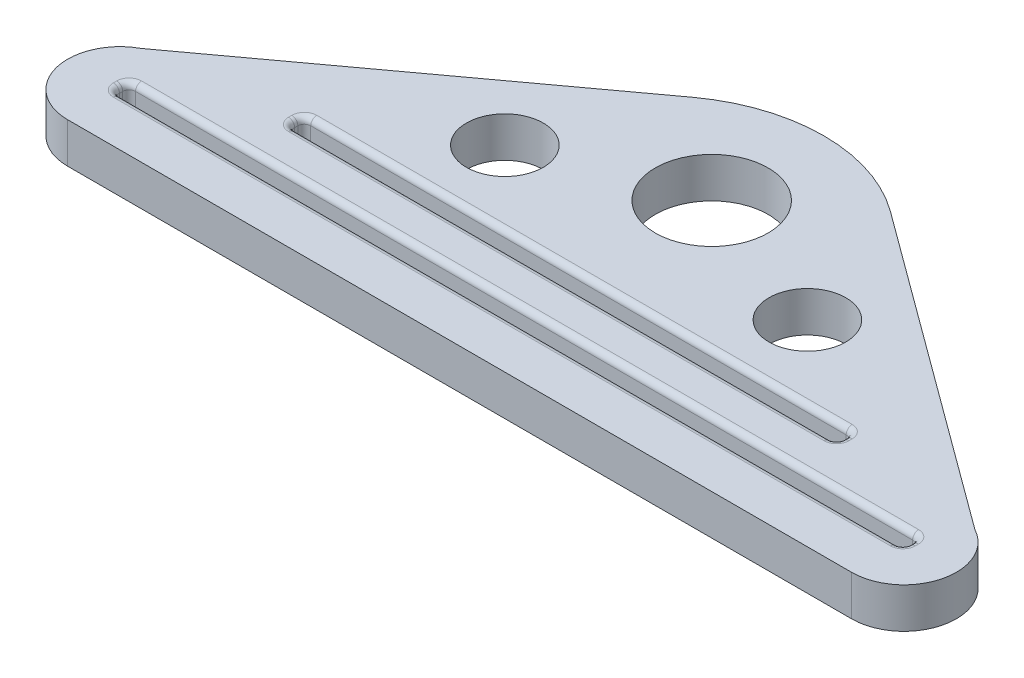
from build123d import *

# Parameters (mm, degrees)
SKETCH1_R           = 4.76718426
SKETCH1_R_2         = 7
BOSS_EXTRUDE1_DEPTH = 5
FILLET1_R           = 0.75


with BuildPart() as part:
    # Sketch1 → Boss-Extrude1 (new body)
    with BuildSketch(Plane(origin=(0, 0, 0), x_dir=(1, 0, 0), z_dir=(0, 1, 0))):
        with BuildLine():
            Line((47.691636032, 41.150111797), (8.289521266, 12.226314063))
            ThreePointArc((8.289521266, 12.226314063), (5.06151148, 4.914289025), (11.365123199, 0))
            Line((11.365123199, 0), (108.634876801, 0))
            ThreePointArc((108.634876801, 0), (114.93848852, 4.914289025), (111.710478734, 12.226314063))
            Line((111.710478734, 12.226314063), (72.308363968, 41.150111797))
            ThreePointArc((72.308363968, 41.150111797), (60, 45.182757312), (47.691636032, 41.150111797))
        make_face()
        with BuildLine():
            Line((108.2, 6), (60, 6))
            Line((60, 6), (11.8, 6))
            ThreePointArc((11.8, 6), (11.234314575, 6.234314575), (11, 6.8))
            Line((11, 6.8), (11, 7.2))
            ThreePointArc((11, 7.2), (11.234314575, 7.765685425), (11.8, 8))
            Line((11.8, 8), (108.2, 8))
            ThreePointArc((108.2, 8), (108.765685425, 7.765685425), (109, 7.2))
            Line((109, 7.2), (109, 6.8))
            ThreePointArc((109, 6.8), (108.765685425, 6.234314575), (108.2, 6))
        make_face(mode=Mode.SUBTRACT)
        with BuildLine():
            Line((92.782659438, 13.175291488), (26.35604376, 13.175291488))
            ThreePointArc((26.35604376, 13.175291488), (25.790358335, 13.409606063), (25.55604376, 13.975291488))
            Line((25.55604376, 13.975291488), (25.55604376, 14.375291488))
            ThreePointArc((25.55604376, 14.375291488), (25.790358335, 14.940976913), (26.35604376, 15.175291488))
            Line((26.35604376, 15.175291488), (92.782659438, 15.175291488))
            ThreePointArc((92.782659438, 15.175291488), (93.348344863, 14.940976913), (93.582659438, 14.375291488))
            Line((93.582659438, 14.375291488), (93.582659438, 13.975291488))
            ThreePointArc((93.582659438, 13.975291488), (93.348344863, 13.409606063), (92.782659438, 13.175291488))
        make_face(mode=Mode.SUBTRACT)
        with Locations((41.231517758, 24.382757312)):
            Circle(SKETCH1_R, mode=Mode.SUBTRACT)
        with Locations((60, 31.276690397)):
            Circle(SKETCH1_R_2, mode=Mode.SUBTRACT)
        with Locations((78.768482242, 24.382757312)):
            Circle(SKETCH1_R, mode=Mode.SUBTRACT)
    extrude(amount=BOSS_EXTRUDE1_DEPTH)

    # Fillet1
    fillet1_edges = [part.edges().sort_by_distance(p)[0] for p in [
        (11.234314575, 5, -7.765685425),
        (11, 5, -7),
        (11.234314575, 0, -6.234314575),
        (60, 5, -6),
        (108.765685425, 5, -6.234314575),
        (109, 5, -7),
        (108.765685425, 0, -7.765685425),
        (60, 5, -8),
        (11.234314575, 5, -6.234314575),
        (108.765685425, 5, -7.765685425),
        (11.234314575, 0, -7.765685425),
        (60, 0, -8),
        (109, 0, -7),
        (108.765685425, 0, -6.234314575),
        (60, 0, -6),
        (11, 0, -7),
        (25.790358335, 5, -14.940976913),
        (25.55604376, 0, -14.175291488),
        (25.790358335, 0, -13.409606063),
        (59.569351599, 0, -13.175291488),
        (93.348344863, 5, -13.409606063),
        (93.582659438, 0, -14.175291488),
        (93.348344863, 0, -14.940976913),
        (59.569351599, 0, -15.175291488),
        (25.55604376, 5, -14.175291488),
        (25.790358335, 5, -13.409606063),
        (59.569351599, 5, -13.175291488),
        (93.582659438, 5, -14.175291488),
        (93.348344863, 5, -14.940976913),
        (59.569351599, 5, -15.175291488),
        (25.790358335, 0, -14.940976913),
        (93.348344863, 0, -13.409606063),
    ]]
    fillet(fillet1_edges, radius=FILLET1_R)


solid = part.part
